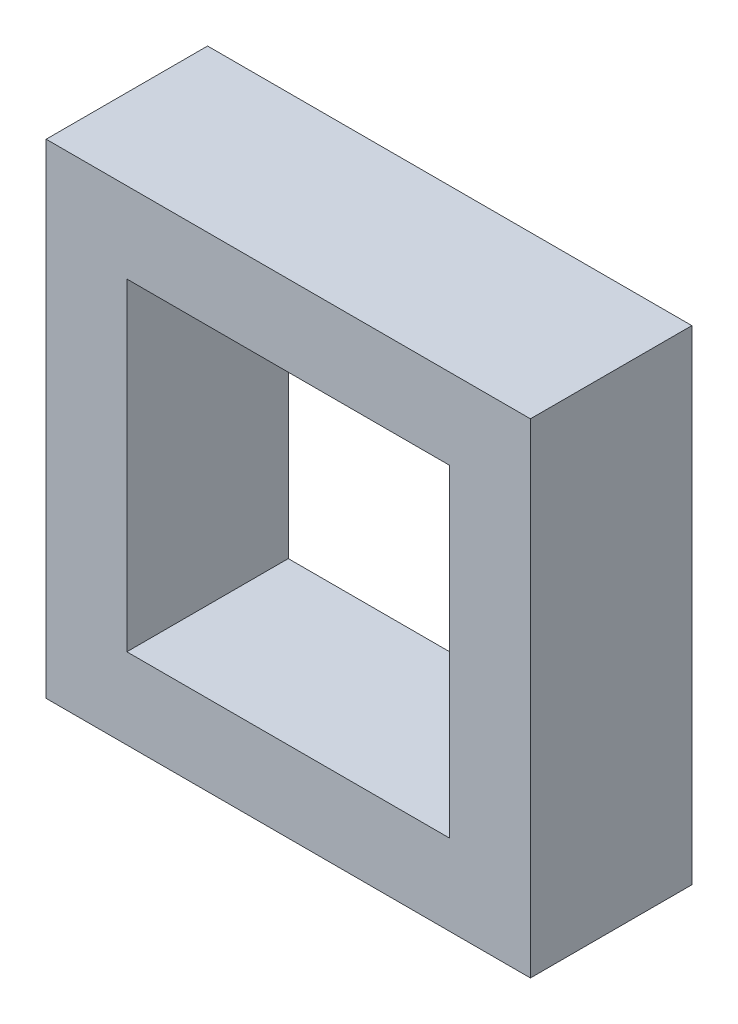
from build123d import *

# Parameters (mm, degrees)
SKETCH1_W           = 6
SKETCH1_H           = 6
SKETCH1_W_2         = 4
SKETCH1_H_2         = 4
BOSS_EXTRUDE1_DEPTH = 2


with BuildPart() as part:
    # Sketch1 → Boss-Extrude1 (new body)
    with BuildSketch(Plane.XY):
        with Locations((2, 2)):
            Rectangle(SKETCH1_W, SKETCH1_H)
        with Locations((2, 2)):
            Rectangle(SKETCH1_W_2, SKETCH1_H_2, mode=Mode.SUBTRACT)
    extrude(amount=BOSS_EXTRUDE1_DEPTH)


solid = part.part
